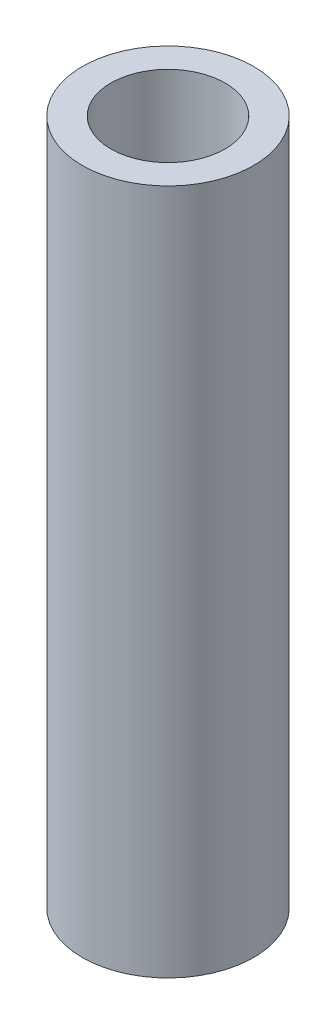
from build123d import *

# Parameters (mm, degrees)
SKETCH1_R           = 7.5
BOSS_EXTRUDE1_DEPTH = 60
SKETCH2_R           = 5
CUT_EXTRUDE1_DEPTH  = 15
SKETCH3_W           = 5.25
SKETCH3_H           = 20.25
CUT_EXTRUDE2_DEPTH  = 7.5


with BuildPart() as part:
    # Sketch1 → Boss-Extrude1 (new body)
    with BuildSketch(Plane(origin=(0, 0, 0), x_dir=(1, 0, 0), z_dir=(0, 1, 0))):
        Circle(SKETCH1_R)
    extrude(amount=BOSS_EXTRUDE1_DEPTH)

    # Sketch2 → Cut-Extrude1 (cut)
    with BuildSketch(Plane(origin=(0, 60, 0), x_dir=(1, 0, 0), z_dir=(0, 1, 0))):
        Circle(SKETCH2_R)
    extrude(amount=-CUT_EXTRUDE1_DEPTH, mode=Mode.SUBTRACT)

    # Sketch3 → Cut-Extrude2 (cut)
    with BuildSketch(Plane(origin=(0, 0, -7.5), x_dir=(-1, 0, 0), z_dir=(0, 0, -1))):
        with Locations((0, 30)):
            Rectangle(SKETCH3_W, SKETCH3_H)
    extrude(amount=-CUT_EXTRUDE2_DEPTH, mode=Mode.SUBTRACT)


solid = part.part
